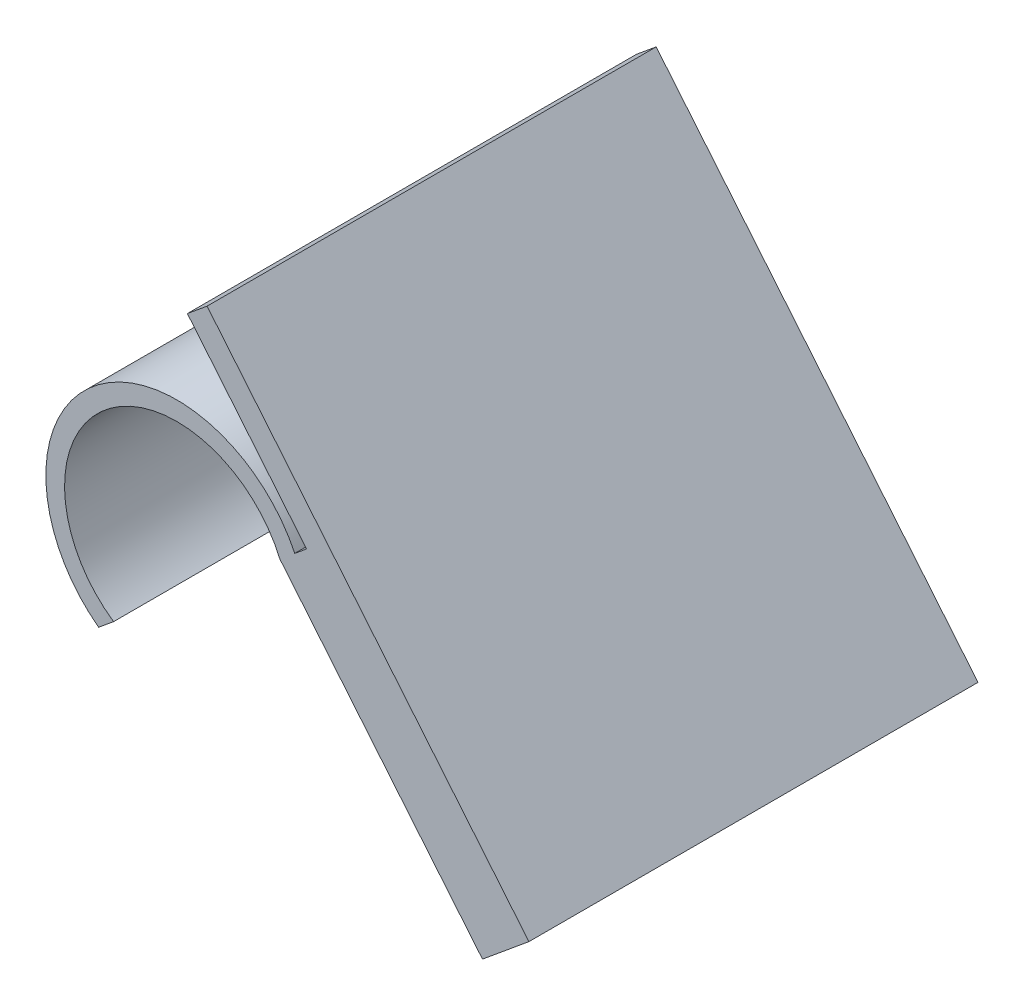
from build123d import *

# Parameters (mm, degrees)
SKETCH2_R           = 44.45
SKETCH2_R_2         = 38.1
BOSS_EXTRUDE1_DEPTH = 152.4
CUT_EXTRUDE1_DEPTH  = 152.4
SKETCH5_W           = 20.435442018
SKETCH5_H           = 152.4
BOSS_EXTRUDE2_DEPTH = 6.35
SKETCH6_W           = 8.676407007
SKETCH6_H           = 152.4
BOSS_EXTRUDE3_DEPTH = 63.5
SKETCH7_W           = 20.435442018
SKETCH7_H           = 152.4
BOSS_EXTRUDE4_DEPTH = 101.6


with BuildPart() as part:
    # Sketch2 → Boss-Extrude1 (new body)
    with BuildSketch(Plane.XY):
        Circle(SKETCH2_R)
        Circle(SKETCH2_R_2, mode=Mode.SUBTRACT)
    extrude(amount=BOSS_EXTRUDE1_DEPTH)

    # Sketch3 → Cut-Extrude1 (cut)
    with BuildSketch(Plane.XY.offset(152.4)):
        Polygon((-26.531587494, -35.663389702), (40.024531053, 19.334927308), (75.854578195, -15.638849725), (-9.866811461, -86.474293044), align=None)
    extrude(amount=-CUT_EXTRUDE1_DEPTH, mode=Mode.SUBTRACT)

    # Sketch5 → Boss-Extrude2 (add)
    with BuildSketch(Plane(origin=(6.746471779, -8.164231197, 0), x_dir=(-0.770864065, -0.63699968, 0), z_dir=(0.63699968, -0.770864065, 0))):
        with Locations((-46.816087742, -76.2)):
            Rectangle(SKETCH5_W, SKETCH5_H)
    extrude(amount=BOSS_EXTRUDE2_DEPTH)

    # Sketch6 → Boss-Extrude3 (add)
    with BuildSketch(Plane(origin=(6.746471779, -8.164231197, 0), x_dir=(0.770864065, 0.63699968, 0), z_dir=(-0.63699968, 0.770864065, 0))):
        with Locations((52.695605247, -76.2)):
            Rectangle(SKETCH6_W, SKETCH6_H)
    extrude(amount=BOSS_EXTRUDE3_DEPTH)

    # Sketch7 → Boss-Extrude4 (add)
    with BuildSketch(Plane(origin=(10.791419749, -13.059218012, 0), x_dir=(0.770864065, 0.63699968, 0), z_dir=(0.63699968, -0.770864065, 0))):
        with Locations((46.816087742, 76.2)):
            Rectangle(SKETCH7_W, SKETCH7_H)
    extrude(amount=BOSS_EXTRUDE4_DEPTH)


solid = part.part
